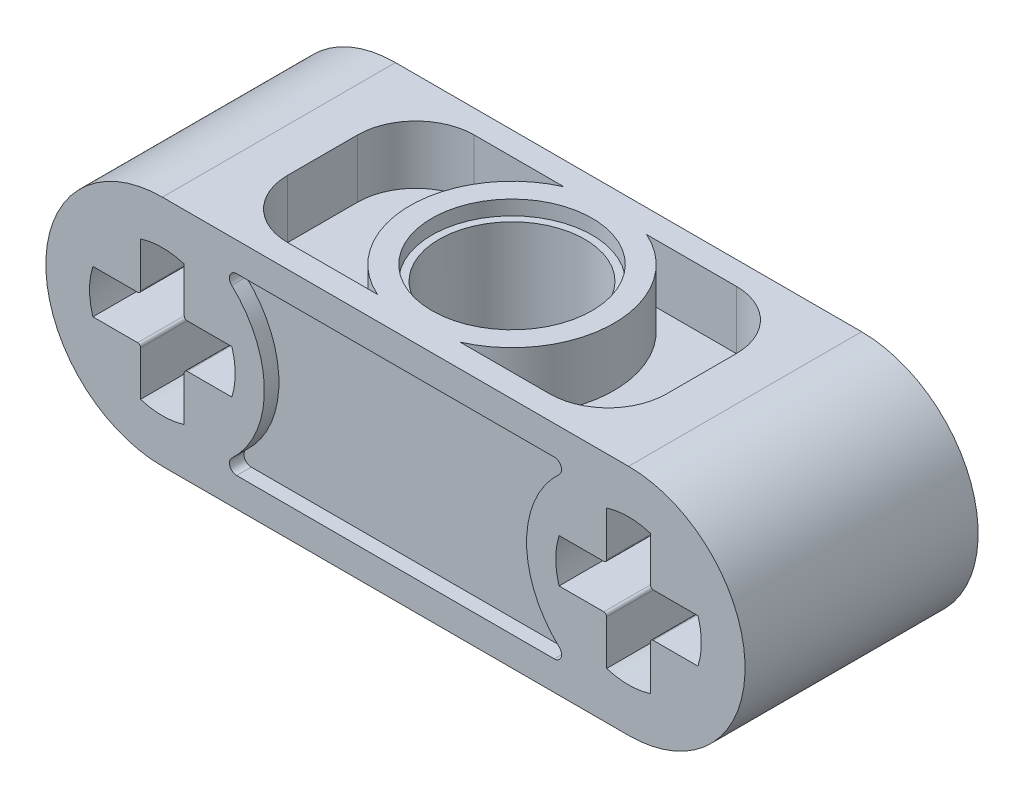
from build123d import *

# Parameters (mm, degrees)
EXTRUIR1_DEPTH         = 4
CROQUIS2_R             = 2.5
CORTAR_EXTRUIR1_DEPTH  = 9
CROQUIS3_R             = 2.75
CORTAR_EXTRUIR2_DEPTH  = 0.5
CORTAR_EXTRUIR3_DEPTH  = 2
SIMETR_A3_COPY_1_DEPTH = 2
REDONDEO1_R            = 2
CORTAR_EXTRUIR4_DEPTH  = 0.5


with BuildPart() as part:
    # Croquis1 → Extruir1 (new body, symmetric)
    with BuildSketch(Plane.XY):
        with BuildLine():
            Line((-8, 4), (8, 4))
            ThreePointArc((8, 4), (12, 0), (8, -4))
            Line((8, -4), (-8, -4))
            ThreePointArc((-8, -4), (-12, 0), (-8, 4))
        make_face()
        with BuildLine():
            Line((10.384848004, -0.75), (8.85, -0.75))
            ThreePointArc((8.85, -0.75), (8.779289322, -0.779289322), (8.75, -0.85))
            Line((8.75, -0.85), (8.75, -2.384848004))
            ThreePointArc((8.75, -2.384848004), (8, -2.5), (7.25, -2.384848004))
            Line((7.25, -2.384848004), (7.25, -0.85))
            ThreePointArc((7.25, -0.85), (7.220710678, -0.779289322), (7.15, -0.75))
            Line((7.15, -0.75), (5.615151996, -0.75))
            ThreePointArc((5.615151996, -0.75), (5.5, 0), (5.615151996, 0.75))
            Line((5.615151996, 0.75), (7.15, 0.75))
            ThreePointArc((7.15, 0.75), (7.220710678, 0.779289322), (7.25, 0.85))
            Line((7.25, 0.85), (7.25, 2.384848004))
            ThreePointArc((7.25, 2.384848004), (8, 2.5), (8.75, 2.384848004))
            Line((8.75, 2.384848004), (8.75, 0.85))
            ThreePointArc((8.75, 0.85), (8.779289322, 0.779289322), (8.85, 0.75))
            Line((8.85, 0.75), (10.384848004, 0.75))
            ThreePointArc((10.384848004, 0.75), (10.5, 0), (10.384848004, -0.75))
        make_face(mode=Mode.SUBTRACT)
        with BuildLine():
            Line((-10.384848004, 0.75), (-8.85, 0.75))
            ThreePointArc((-8.85, 0.75), (-8.779289322, 0.779289322), (-8.75, 0.85))
            Line((-8.75, 0.85), (-8.75, 2.384848004))
            ThreePointArc((-8.75, 2.384848004), (-8, 2.5), (-7.25, 2.384848004))
            Line((-7.25, 2.384848004), (-7.25, 0.85))
            ThreePointArc((-7.25, 0.85), (-7.220710678, 0.779289322), (-7.15, 0.75))
            Line((-7.15, 0.75), (-5.615151996, 0.75))
            ThreePointArc((-5.615151996, 0.75), (-5.5, 0), (-5.615151996, -0.75))
            Line((-5.615151996, -0.75), (-7.15, -0.75))
            ThreePointArc((-7.15, -0.75), (-7.220710678, -0.779289322), (-7.25, -0.85))
            Line((-7.25, -0.85), (-7.25, -2.384848004))
            ThreePointArc((-7.25, -2.384848004), (-8, -2.5), (-8.75, -2.384848004))
            Line((-8.75, -2.384848004), (-8.75, -0.85))
            ThreePointArc((-8.75, -0.85), (-8.779289322, -0.779289322), (-8.85, -0.75))
            Line((-8.85, -0.75), (-10.384848004, -0.75))
            ThreePointArc((-10.384848004, -0.75), (-10.5, 0), (-10.384848004, 0.75))
        make_face(mode=Mode.SUBTRACT)
    extrude(amount=EXTRUIR1_DEPTH, both=True)

    # Croquis2 → Cortar-Extruir1 (cut, through all)
    with BuildSketch(Plane(origin=(0, 4, 0), x_dir=(-1, 0, 0), z_dir=(0, 1, 0))):
        Circle(CROQUIS2_R)
    extrude(amount=-CORTAR_EXTRUIR1_DEPTH, mode=Mode.SUBTRACT)

    # Croquis3 → Cortar-Extruir2 (cut)
    with BuildSketch(Plane(origin=(0, 4, 0), x_dir=(-1, 0, 0), z_dir=(0, 1, 0))):
        Circle(CROQUIS3_R)
    cortar_extruir2 = extrude(amount=-CORTAR_EXTRUIR2_DEPTH, mode=Mode.SUBTRACT)

    # Simetría1: Cortar-Extruir2 across plane
    add(cortar_extruir2.mirror(Plane.ZX), mode=Mode.SUBTRACT)

    # Croquis4 → Cortar-Extruir3 (cut)
    with BuildSketch(Plane(origin=(0, 4, 0), x_dir=(-1, 0, 0), z_dir=(0, 1, 0))):
        with BuildLine():
            Line((-1.417744688, -3.2), (-6.5, -3.2))
            Line((-6.5, -3.2), (-6.5, 3.2))
            Line((-6.5, 3.2), (-1.417744688, 3.2))
            ThreePointArc((-1.417744688, 3.2), (-3.5, 0), (-1.417744688, -3.2))
        make_face()
    cortar_extruir3 = extrude(amount=-CORTAR_EXTRUIR3_DEPTH, mode=Mode.SUBTRACT)

    # Simetría2: Cortar-Extruir3 across plane
    add(cortar_extruir3.mirror(Plane(origin=(0, 0, 0), x_dir=(0, 0, 1), z_dir=(1, 0, 0))), mode=Mode.SUBTRACT)

    # Simetría3: Cortar-Extruir3 across plane
    add(cortar_extruir3.mirror(Plane.ZX), mode=Mode.SUBTRACT)

    # Simetría3 copy 1 sketch → Simetría3 copy 1 (cut)
    with BuildSketch(Plane.XZ.offset(4)):
        with BuildLine():
            Line((-1.417744688, -3.2), (-6.5, -3.2))
            Line((-6.5, -3.2), (-6.5, 3.2))
            Line((-6.5, 3.2), (-1.417744688, 3.2))
            ThreePointArc((-1.417744688, 3.2), (-3.5, 0), (-1.417744688, -3.2))
        make_face()
    extrude(amount=-SIMETR_A3_COPY_1_DEPTH, mode=Mode.SUBTRACT)

    # Redondeo1
    redondeo1_edges = [part.edges().sort_by_distance(p)[0] for p in [
        (6.5, 3, -3.2),
        (6.5, 3, 3.2),
        (-6.5, 3, 3.2),
        (-6.5, 3, -3.2),
        (-6.5, -3, -3.2),
        (-6.5, -3, 3.2),
        (6.5, -3, 3.2),
        (6.5, -3, -3.2),
    ]]
    fillet(redondeo1_edges, radius=REDONDEO1_R)

    # Croquis5 → Cortar-Extruir4 (cut)
    with BuildSketch(Plane.XY.offset(4)):
        with BuildLine():
            Line((-5.450490243, 3), (5.450490243, 3))
            ThreePointArc((5.450490243, 3), (5.683227577, 2.841287093), (5.62045756, 2.566666667))
            ThreePointArc((5.62045756, 2.566666667), (4.5, 0), (5.62045756, -2.566666667))
            ThreePointArc((5.62045756, -2.566666667), (5.683227577, -2.841287093), (5.450490243, -3))
            Line((5.450490243, -3), (-5.450490243, -3))
            ThreePointArc((-5.450490243, -3), (-5.683227577, -2.841287093), (-5.62045756, -2.566666667))
            ThreePointArc((-5.62045756, -2.566666667), (-4.5, 0), (-5.62045756, 2.566666667))
            ThreePointArc((-5.62045756, 2.566666667), (-5.683227577, 2.841287093), (-5.450490243, 3))
        make_face()
    cortar_extruir4 = extrude(amount=-CORTAR_EXTRUIR4_DEPTH, mode=Mode.SUBTRACT)

    # Simetría4: Cortar-Extruir4 across plane
    add(cortar_extruir4.mirror(Plane.XY), mode=Mode.SUBTRACT)


solid = part.part
